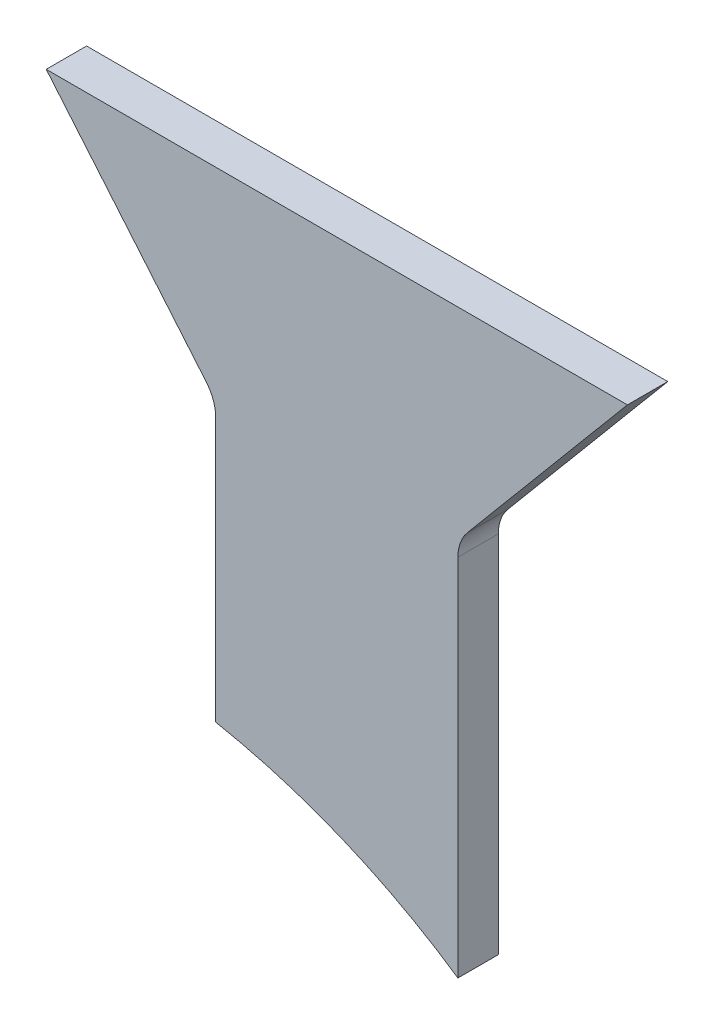
from build123d import *

# Parameters (mm, degrees)
FUNNEL_SIDE_PANEL_DEPTH = 10
FILLET1_R               = 10


with BuildPart() as part:
    # Sketch1 → Funnel - Side Panel (new body)
    with BuildSketch(Plane.XY):
        with BuildLine():
            Line((30, 0), (30, 93.9))
            Line((30, 93.9), (71.974030913, 143.922702136))
            Line((71.974030913, 143.922702136), (-71.974030913, 143.922702136))
            Line((-71.974030913, 143.922702136), (-30, 93.9))
            Line((-30, 93.9), (-30, 24.874770902))
            ThreePointArc((-30, 24.874770902), (1.275513518, 15.514029307), (30, 0))
        make_face()
    extrude(amount=FUNNEL_SIDE_PANEL_DEPTH)

    # Fillet1
    fillet1_edges = [part.edges().sort_by_distance(p)[0] for p in [
        (-30, 93.9, 5),
        (30, 93.9, 5),
    ]]
    fillet(fillet1_edges, radius=FILLET1_R)


solid = part.part
